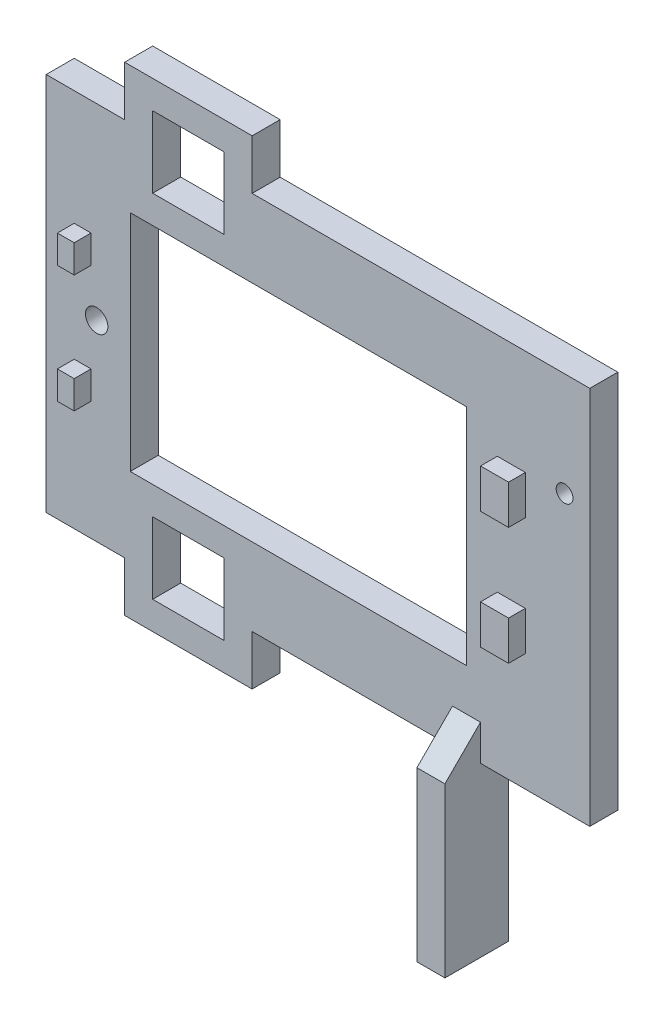
from build123d import *

# Parameters (mm, degrees)
SKETCH1_W           = 97
SKETCH1_H           = 67.7
BOSS_EXTRUDE1_DEPTH = 5
SKETCH2_R           = 2
SKETCH2_R_2         = 1.5
SKETCH2_W           = 60
SKETCH2_H           = 40
CUT_EXTRUDE1_DEPTH  = 6
SKETCH3_W           = 3
SKETCH3_H           = 5
SKETCH3_W_2         = 5
SKETCH3_H_2         = 7
BOSS_EXTRUDE2_DEPTH = 3
SKETCH7_W           = 5
SKETCH7_H           = 11.35
BOSS_EXTRUDE4_DEPTH = 30
BOSS_EXTRUDE5_DEPTH = 5
SKETCH4_W           = 12.75
SKETCH4_H           = 12.75
CUT_EXTRUDE2_DEPTH  = 12.35
BOSS_EXTRUDE6_DEPTH = 5


with BuildPart() as part:
    # Sketch1 → Boss-Extrude1 (new body)
    with BuildSketch(Plane.XY):
        with Locations((-48.5, 33.85)):
            Rectangle(SKETCH1_W, SKETCH1_H)
    extrude(amount=BOSS_EXTRUDE1_DEPTH)

    # Sketch2 → Cut-Extrude1 (cut, through all)
    with BuildSketch(Plane.XY.offset(5)):
        with Locations((-88, 34.2)):
            Circle(SKETCH2_R)
        with Locations((-4.5, 49.2)):
            Circle(SKETCH2_R_2)
        with Locations((-52, 33.85)):
            Rectangle(SKETCH2_W, SKETCH2_H)
    extrude(amount=-CUT_EXTRUDE1_DEPTH, mode=Mode.SUBTRACT)

    # Sketch3 → Boss-Extrude2 (add)
    with BuildSketch(Plane.XY.offset(5)):
        with Locations((-90.5, 44.7)):
            Rectangle(SKETCH3_W, SKETCH3_H)
        with Locations((-90.5, 23.7)):
            Rectangle(SKETCH3_W, SKETCH3_H)
        with Locations((-14, 45.45)):
            Rectangle(SKETCH3_W_2, SKETCH3_H_2)
        with Locations((-14, 24.45)):
            Rectangle(SKETCH3_W_2, SKETCH3_H_2)
    extrude(amount=BOSS_EXTRUDE2_DEPTH)

    # Sketch7 → Boss-Extrude4 (add)
    with BuildSketch(Plane.XZ):
        with Locations((-22, 5.675)):
            Rectangle(SKETCH7_W, SKETCH7_H)
    extrude(amount=BOSS_EXTRUDE4_DEPTH)

    # Sketch8 → Boss-Extrude5 (add)
    with BuildSketch(Plane(origin=(-19.5, 0, 0), x_dir=(0, 0, -1), z_dir=(1, 0, 0))):
        Polygon((-11.35, 0), (-5, 0), (-5, 6.35), align=None)
    extrude(amount=-BOSS_EXTRUDE5_DEPTH)

    # Sketch4 → Cut-Extrude2 (cut, through all)
    with BuildSketch(Plane(origin=(0, 0, 0), x_dir=(-1, 0, 0), z_dir=(0, 0, -1))):
        with Locations((71.625, 65.225)):
            Rectangle(SKETCH4_W, SKETCH4_H)
        with Locations((71.625, 2.475)):
            Rectangle(SKETCH4_W, SKETCH4_H)
    extrude(amount=-CUT_EXTRUDE2_DEPTH, mode=Mode.SUBTRACT)

    # Sketch10 → Boss-Extrude6 (add)
    with BuildSketch(Plane(origin=(0, 0, 0), x_dir=(-1, 0, 0), z_dir=(0, 0, -1))):
        Polygon((83, 0), (83, -8.9), (60.25, -8.9), (60.25, 0), (65.25, 0), (65.25, -3.9), (78, -3.9), (78, 0), align=None)
        Polygon((83, 67.7), (78, 67.7), (78, 71.6), (65.25, 71.6), (65.25, 67.7), (60.25, 67.7), (60.25, 76.6), (83, 76.6), align=None)
    extrude(amount=-BOSS_EXTRUDE6_DEPTH)


solid = part.part
